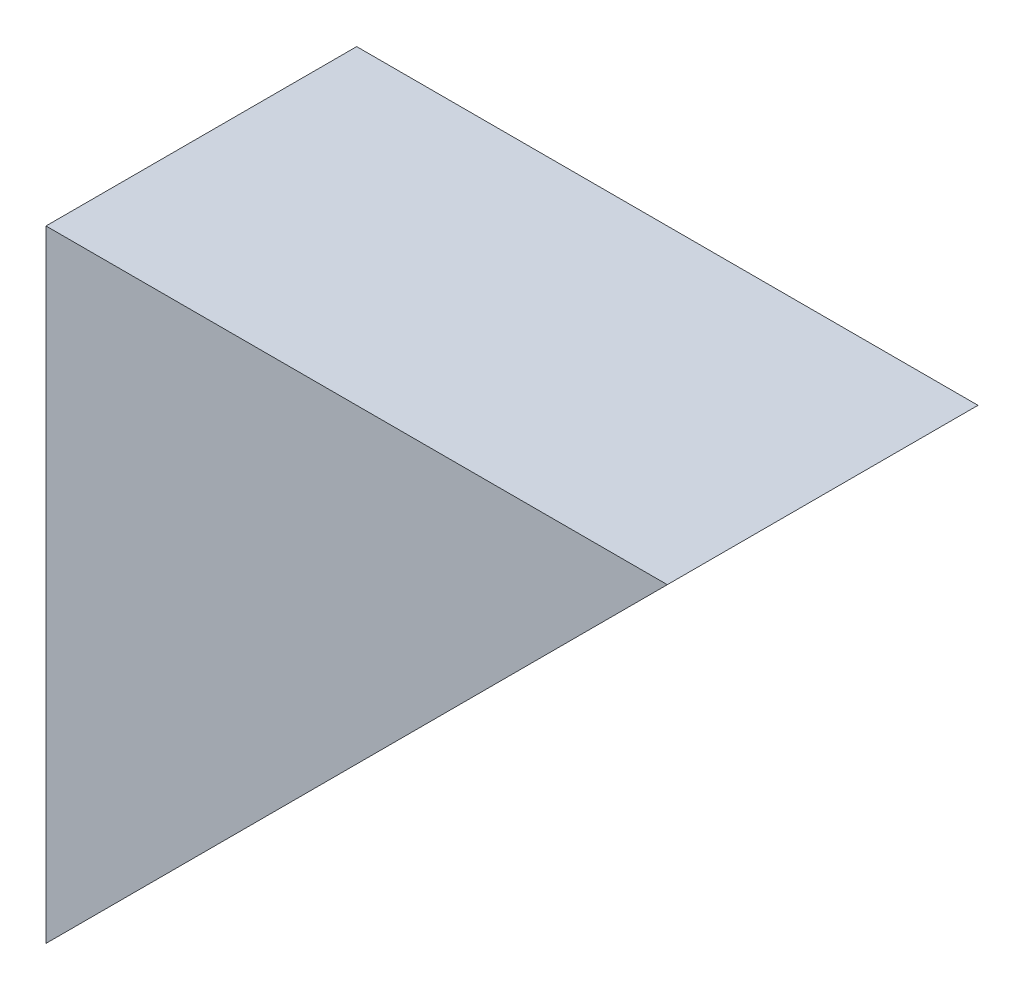
from build123d import *

# Parameters (mm, degrees)
BOSS_EXTRUDE2_DEPTH = 12.7
SKETCH5_R           = 2.25
CUT_EXTRUDE1_DEPTH  = 26.4
SKETCH6_R           = 4.5
CUT_EXTRUDE2_DEPTH  = 17.51


with BuildPart() as part:
    # xs → Boss-Extrude2 (new body)
    with BuildSketch(Plane.XY):
        Polygon((-108.204482014, 92.076361751), (-108.204482014, 66.676361751), (-82.804482014, 92.076361751), align=None)
    extrude(amount=-BOSS_EXTRUDE2_DEPTH)

    # Sketch5 → Cut-Extrude1 (cut, through all)
    with BuildSketch(Plane.ZY.offset(108.204482014)):
        with Locations((-6.35, 79.376361751)):
            Circle(SKETCH5_R)
    extrude(amount=-CUT_EXTRUDE1_DEPTH, mode=Mode.SUBTRACT)

    # Sketch6 → Cut-Extrude2 (cut, through all)
    with BuildSketch(Plane.ZY.offset(99.314482014)):
        with Locations((-6.35, 79.376361751)):
            Circle(SKETCH6_R)
    extrude(amount=-CUT_EXTRUDE2_DEPTH, mode=Mode.SUBTRACT)


solid = part.part
